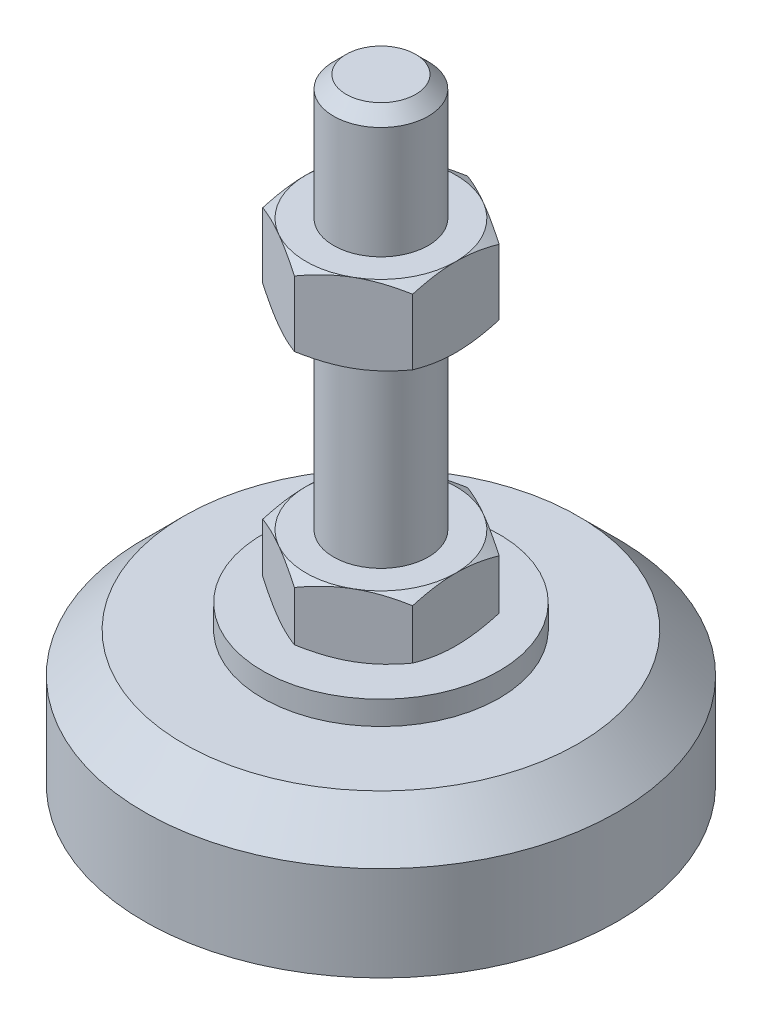
from build123d import *

# Parameters (mm, degrees)
EXTRUDE_1_DEPTH = 8
EXTRUDE_2_DEPTH = 10


with BuildPart() as part:
    # Эскиз1 → Повернуть1 (revolve)
    with BuildSketch(Plane.XY, mode=Mode.PRIVATE) as revolve_1_sk:
        Polygon((0, 0), (-30, 0), (-30, 12), (-25, 17), (-15, 17), (-15, 20), (-6, 20), (-6, 28), (-6, 76.4), (-4.4, 78), (0, 78), align=None)
    revolve(revolve_1_sk.sketch.rotate(Axis((0, 0, 0), (0, 1, 0)), 180), axis=Axis((0, 0, 0), (0, 1, 0)))  # turned: the seam where the file's is

    # Эскиз2 → Бобышка-Вытянуть1 (add)
    with BuildSketch(Plane(origin=(0, 20, 0), x_dir=(1, 0, 0), z_dir=(0, 1, 0))):
        Polygon((0, 10.969655115), (-9.5, 5.484827557), (-9.5, -5.484827557), (0, -10.969655115), (9.5, -5.484827557), (9.5, 5.484827557), align=None)
    extrude(amount=EXTRUDE_1_DEPTH)

    # Эскиз3 → Бобышка-Вытянуть2 (add)
    with BuildSketch(Plane(origin=(0, 52.2, 0), x_dir=(1, 0, 0), z_dir=(0, 1, 0))):
        Polygon((9.5, 5.484827557), (0, 10.969655115), (-9.5, 5.484827557), (-9.5, -5.484827557), (0, -10.969655115), (9.5, -5.484827557), align=None)
    extrude(amount=EXTRUDE_2_DEPTH)

    # Эскиз4 → Вырез-Повернуть2 (revolve, cut)
    with BuildSketch(Plane.XY, mode=Mode.PRIVATE) as cut_revolve_2_sk:
        Polygon((-18.160254038, 62.2), (-9.5, 62.2), (-18.160254038, 57.2), align=None)
        Polygon((-18.160254038, 52.2), (-18.160254038, 57.2), (-9.5, 52.2), align=None)
        Polygon((-16.42820323, 28), (-16.42820323, 24), (-9.5, 28), align=None)
        Polygon((-16.42820323, 24), (-16.42820323, 20), (-9.5, 20), align=None)
    revolve(cut_revolve_2_sk.sketch.rotate(Axis((0, 78, 0), (0, 1, 0)), 180), axis=Axis((0, 78, 0), (0, 1, 0)), mode=Mode.SUBTRACT)  # turned: the seam where the file's is


solid = part.part
